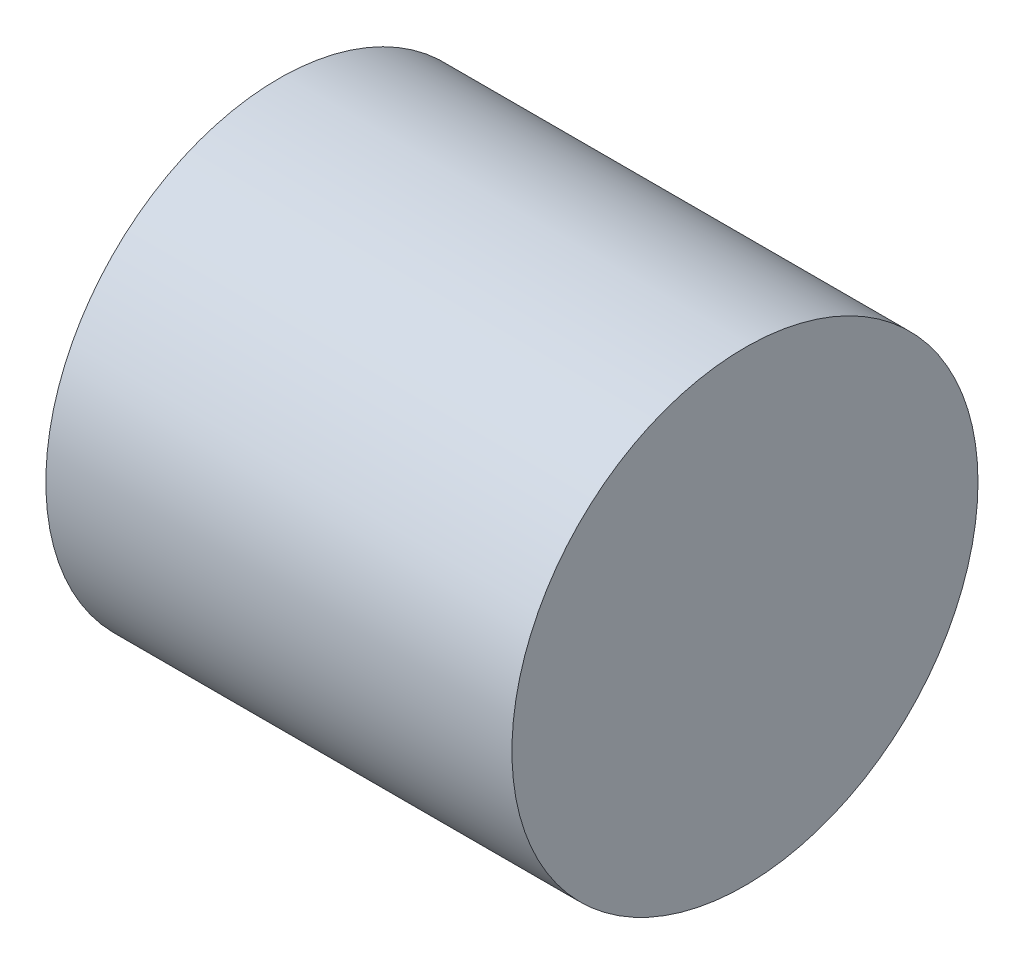
from build123d import *

# Parameters (mm, degrees)
SKETCH1_R      = 9.525
EXTRUDE1_DEPTH = 19.05


with BuildPart() as part:
    # Sketch1 → Extrude1 (new body)
    with BuildSketch(Plane(origin=(0, 0, 0), x_dir=(0, 0, -1), z_dir=(1, 0, 0))):
        with Locations((-77.09474291, 47.452624521)):
            Circle(SKETCH1_R)
    extrude(amount=EXTRUDE1_DEPTH)


solid = part.part
